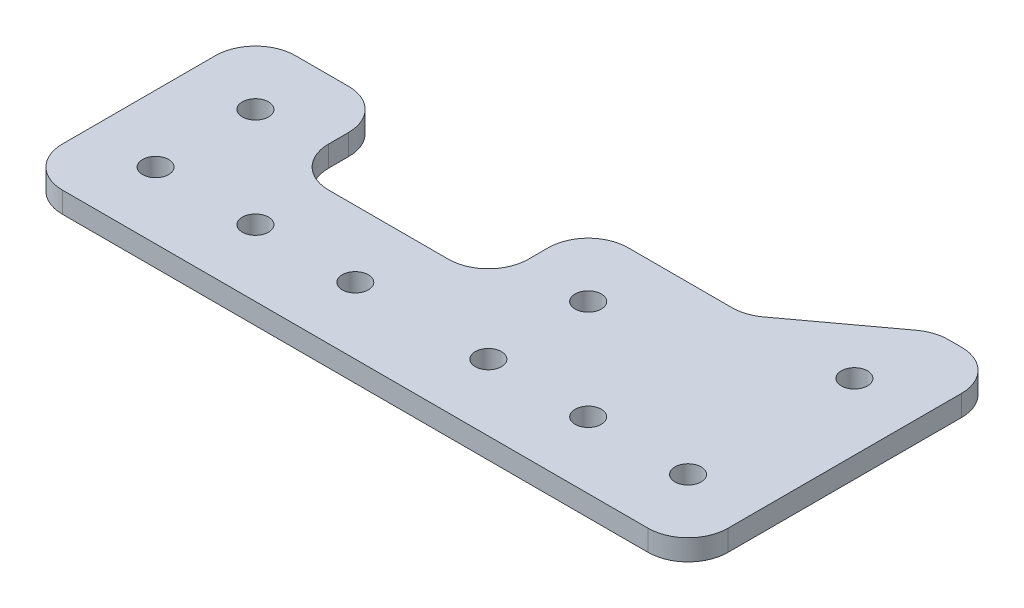
from build123d import *

# Parameters (mm, degrees)
SKETCH1_R           = 2.5
BOSS_EXTRUDE1_DEPTH = 4
FILLET1_R           = 7.62


with BuildPart() as part:
    # Sketch1 → Boss-Extrude1 (new body)
    with BuildSketch(Plane(origin=(0, 25.4, 0), x_dir=(1, 0, 0), z_dir=(0, 1, 0))):
        Polygon((-127, -260.35), (-97.035940071, -260.35), (-76.2, -244.98413998), (-63.5, -244.98413998), (-63.5, -304.8), (-190.5, -304.8), (-190.5, -279.4), (-190.5, -260.35), (-165.1, -260.35), (-165.1, -279.4), (-127, -279.4), align=None)
        with Locations((-114.3, -292.1)):
            Circle(SKETCH1_R, mode=Mode.SUBTRACT)
        with Locations((-177.8, -292.1)):
            Circle(SKETCH1_R, mode=Mode.SUBTRACT)
        with Locations((-158.75, -292.1)):
            Circle(SKETCH1_R, mode=Mode.SUBTRACT)
        with Locations((-95.25, -292.1)):
            Circle(SKETCH1_R, mode=Mode.SUBTRACT)
        with Locations((-139.7, -292.1)):
            Circle(SKETCH1_R, mode=Mode.SUBTRACT)
        with Locations((-76.2, -292.1)):
            Circle(SKETCH1_R, mode=Mode.SUBTRACT)
        with Locations((-114.3, -273.05)):
            Circle(SKETCH1_R, mode=Mode.SUBTRACT)
        with Locations((-177.8, -273.05)):
            Circle(SKETCH1_R, mode=Mode.SUBTRACT)
        with Locations((-76.2, -260.35)):
            Circle(SKETCH1_R, mode=Mode.SUBTRACT)
    extrude(amount=BOSS_EXTRUDE1_DEPTH)

    # Fillet1
    fillet1_edges = [part.edges().sort_by_distance(p)[0] for p in [
        (-190.5, 27.4, 304.8),
        (-190.5, 27.4, 260.35),
        (-165.1, 27.4, 260.35),
        (-165.1, 27.4, 279.4),
        (-127, 27.4, 279.4),
        (-127, 27.4, 260.35),
        (-97.035940071, 27.4, 260.35),
        (-76.2, 27.4, 244.98413998),
        (-63.5, 27.4, 244.98413998),
        (-63.5, 27.4, 304.8),
    ]]
    fillet(fillet1_edges, radius=FILLET1_R)


solid = part.part
